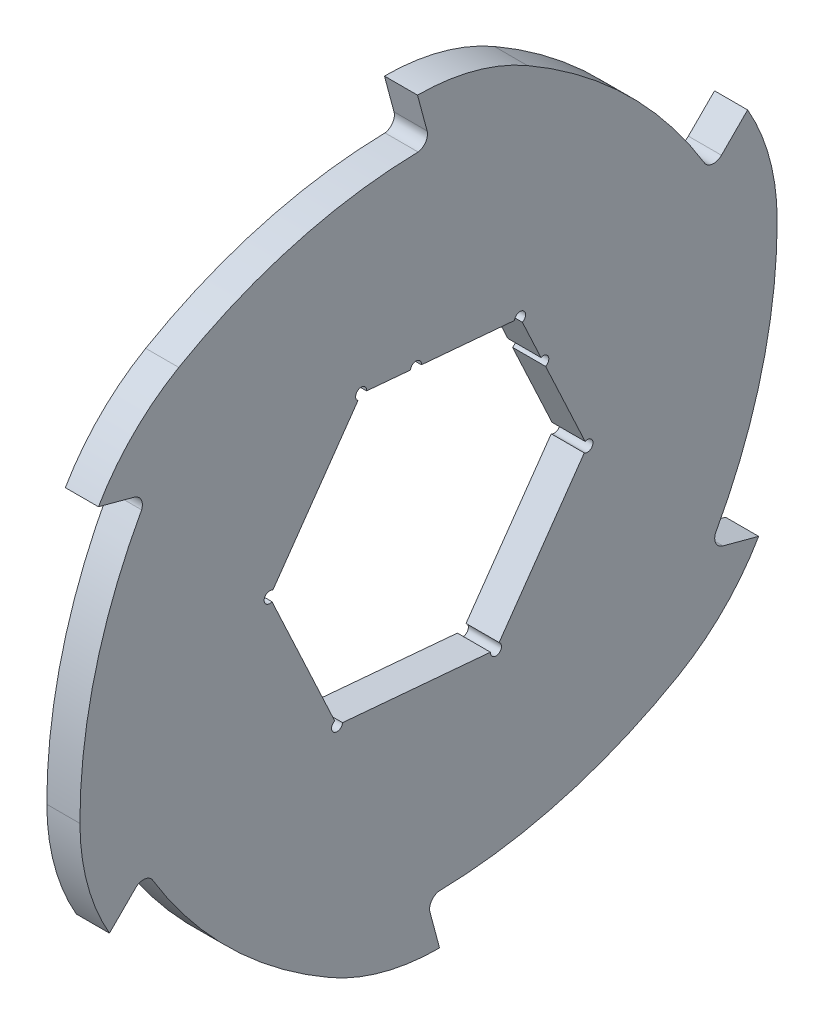
from build123d import *

# Parameters (mm, degrees)
SKETCH1_R                = 59
EXTRUDE1_DEPTH           = 3
EXTRUDE2_DEPTH           = 3
CIRPATTERN1_COUNT        = 6
F_2_0_2_DIAMETER_HOLE1_D = 2
F_2_0_2_DIAMETER_HOLE3_D = 2
CIRPATTERN2_COUNT        = 2
CIRPATTERN2_ANGLE        = 60


with BuildPart() as part:
    # Sketch1 → Extrude1 (new, symmetric)
    with BuildSketch(Plane(origin=(0, 0, 0), x_dir=(0, 0, -1), z_dir=(1, 0, 0))):
        Circle(SKETCH1_R)
        Polygon((16.590840947, 23.694176429), (-12.224338236, 26.215177945), (-28.815179183, 2.521001516), (-16.590840947, -23.694176429), (12.224338236, -26.215177945), (28.815179183, -2.521001516), align=None, mode=Mode.SUBTRACT)
    extrude(amount=EXTRUDE1_DEPTH, both=True)

    # Sketch2 → Extrude2 (add, symmetric)
    with BuildSketch(Plane(origin=(0, 0, 0), x_dir=(0, 0, -1), z_dir=(1, 0, 0))):
        with BuildLine():
            Line((-2, 67.961805723), (-0.262709442, 61.478149092))
            ThreePointArc((-0.262709442, 61.478149092), (-0.58620663, 59.77173183), (-2.122608272, 58.961805723))
            ThreePointArc((-2.122608272, 58.961805723), (28.679663449, 51.560419941), (51.21368579, 29.294340542))
            ThreePointArc((51.21368579, 29.294340542), (36.791707484, 48.186627241), (17.927108603, 62.644803614))
            ThreePointArc((17.927108603, 62.644803614), (8.312130826, 66.609702921), (-2, 67.961805723))
        make_face()
    extrude2 = extrude(amount=EXTRUDE2_DEPTH, both=True)

    # CirPattern1: Extrude2 ×6 about axis
    cirpattern1_axis = Axis((0, 0, 0), (1, 0, 0))
    for i in range(1, CIRPATTERN1_COUNT):
        add(extrude2.rotate(cirpattern1_axis, i * 360 / CIRPATTERN1_COUNT))

    # Ø2.0 (2) Diameter Hole1 (through all)
    with Locations(Plane(origin=(3, 0, 0), x_dir=(0, 0, -1), z_dir=(1, 0, 0))):
        with Locations((-12.224338236, 26.215177945), (16.590840947, 23.694176429), (28.815179183, -2.521001516), (12.224338236, -26.215177945), (-16.590840947, -23.694176429), (-28.815179183, 2.521001516)):
            Hole(F_2_0_2_DIAMETER_HOLE1_D / 2)

    # Ø2.0 (2) Diameter Hole3 (through all)
    with Locations(Plane(origin=(3, 0, 0), x_dir=(0, 0, -1), z_dir=(1, 0, 0))):
        with Locations((-2.287213609, 25.345792192)):
            f_2_0_2_diameter_hole3 = Hole(F_2_0_2_DIAMETER_HOLE3_D / 2)

    # CirPattern2: Ø2.0 (2) Diameter Hole3 ×2 about axis
    cirpattern2_axis = Axis((-5.5, 0, 0), (-1, 0, 0))
    for i in range(1, CIRPATTERN2_COUNT):
        add(f_2_0_2_diameter_hole3.rotate(cirpattern2_axis, i * CIRPATTERN2_ANGLE / (CIRPATTERN2_COUNT - 1)), mode=Mode.SUBTRACT)


solid = part.part
